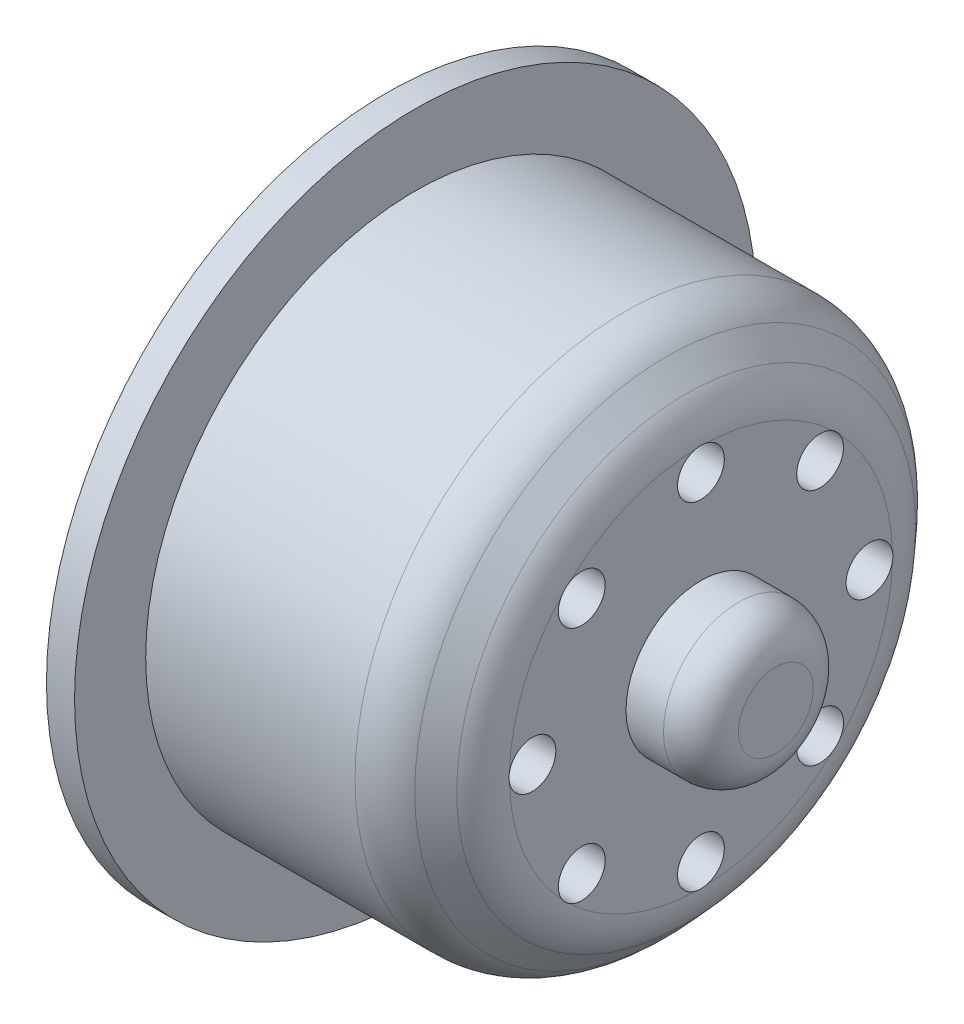
from build123d import *

# Parameters (mm, degrees)
FILLET1_R          = 2
SKETCH4_R          = 10.5
CUT_EXTRUDE3_DEPTH = 6
SKETCH5_R          = 1.25
CUT_EXTRUDE4_DEPTH = 16.75
SKETCH6_R          = 2.5
CUT_EXTRUDE5_DEPTH = 11.75
FILLET2_R          = 3


with BuildPart() as part:
    # Sketch1 → Revolve1 (revolve)
    with BuildSketch(Plane(origin=(0, 0, 0), x_dir=(1, 0, 0), z_dir=(0, 1, 0))):
        Polygon((-4.630434783, 14.4), (7.869565217, 14.4), (10.619565217, 11.390476118), (10.619565217, 4), (14.619565217, 4), (14.619565217, 0), (13.372742768, 0), (-6.130434783, 0), (-6.130434783, 18.2), (-4.630434783, 18.2), align=None)
    revolve(axis=Axis((-12.391304348, 0, 0), (1, 0, 0)))

    # Fillet1
    fillet1_edges = [part.edges().sort_by_distance(p)[0] for p in [
        (14.619565217, 0, 4),
    ]]
    fillet(fillet1_edges, radius=FILLET1_R)

    # Sketch4 → Cut-Extrude3 (cut)
    with BuildSketch(Plane.ZY.offset(6.130434783)):
        Circle(SKETCH4_R)
    extrude(amount=-CUT_EXTRUDE3_DEPTH, mode=Mode.SUBTRACT)

    # Sketch5 → Cut-Extrude4 (cut)
    with BuildSketch(Plane(origin=(10.619565217, 0, 0), x_dir=(0, 0, -1), z_dir=(1, 0, 0))):
        with Locations((0, 9)):
            Circle(SKETCH5_R)
        with Locations((6.363961031, 6.363961031)):
            Circle(SKETCH5_R)
        with Locations((9, 0)):
            Circle(SKETCH5_R)
        with Locations((6.363961031, -6.363961031)):
            Circle(SKETCH5_R)
        with Locations((0, -9)):
            Circle(SKETCH5_R)
        with Locations((-6.363961031, -6.363961031)):
            Circle(SKETCH5_R)
        with Locations((-9, 0)):
            Circle(SKETCH5_R)
        with Locations((-6.363961031, 6.363961031)):
            Circle(SKETCH5_R)
    extrude(amount=-CUT_EXTRUDE4_DEPTH, mode=Mode.SUBTRACT)

    # Sketch6 → Cut-Extrude5 (cut)
    with BuildSketch(Plane.ZY.offset(6.130434783)):
        with Locations((0, 9)):
            Circle(SKETCH6_R)
        with Locations((6.363961031, 6.363961031)):
            Circle(SKETCH6_R)
        with Locations((9, 0)):
            Circle(SKETCH6_R)
        with Locations((6.363961031, -6.363961031)):
            Circle(SKETCH6_R)
        with Locations((0, -9)):
            Circle(SKETCH6_R)
        with Locations((-6.363961031, -6.363961031)):
            Circle(SKETCH6_R)
        with Locations((-9, 0)):
            Circle(SKETCH6_R)
        with Locations((-6.363961031, 6.363961031)):
            Circle(SKETCH6_R)
    extrude(amount=-CUT_EXTRUDE5_DEPTH, mode=Mode.SUBTRACT)

    # Fillet2
    fillet2_edges = [part.edges().sort_by_distance(p)[0] for p in [
        (7.869565217, 0, 14.4),
        (10.619565217, 0, 11.390476118),
    ]]
    fillet(fillet2_edges, radius=FILLET2_R)


solid = part.part
